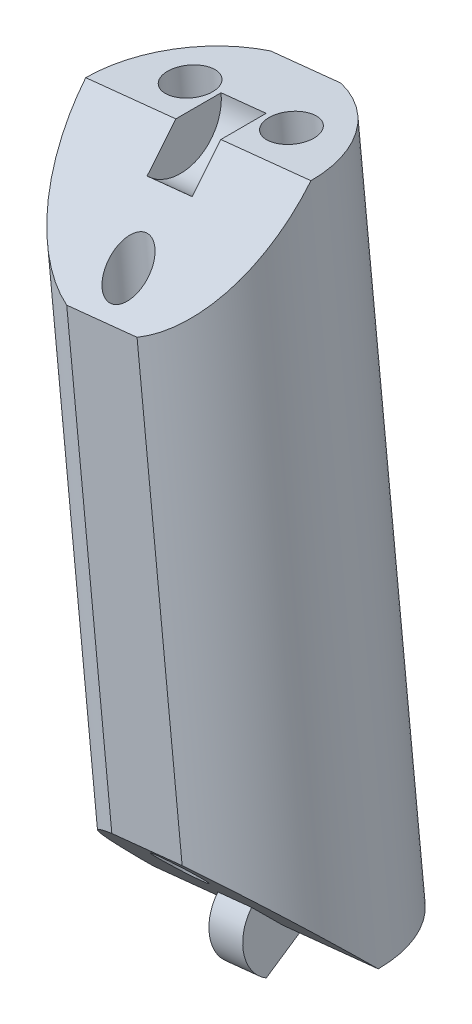
from build123d import *

# Parameters (mm, degrees)
SKETCH3_R               = 8
BOSS_EXTRUDE1_DEPTH     = 46.103684211
CUT_EXTRUDE1_DEPTH      = 13.730251515
CUT_EXTRUDE1_DEPTH_BACK = 13.730251515
BOSS_EXTRUDE2_DEPTH     = 1.2
CUT_EXTRUDE2_DEPTH      = 1.6
SKETCH8_R               = 1.4
SKETCH8_R_2             = 1.6
CUT_EXTRUDE3_DEPTH      = 2.64160469
CUT_EXTRUDE3_DEPTH_BACK = 50.446677335
CUT_EXTRUDE4_DEPTH      = 50.446677335


with BuildPart() as part:
    # Sketch3 → Boss-Extrude1 (new body)
    with BuildSketch(Plane(origin=(-20.344467381, 196.178792599, 0), x_dir=(-0.994665758, -0.103150523, 0), z_dir=(0.103150523, -0.994665758, 0))):
        with Locations((-10.431405186, 0)):
            Circle(SKETCH3_R)
    extrude(amount=BOSS_EXTRUDE1_DEPTH)

    # Sketch4 → Cut-Extrude1 (cut, two sides)
    with BuildSketch(Plane(origin=(10.375761543, 1.076004901, 0), x_dir=(0.103150523, -0.994665758, 0), z_dir=(-0.994665758, -0.103150523, 0))) as cut_extrude1_sk:
        Polygon((-197.230869842, 0), (-189.230869842, 8), (-197.230869842, 8), align=None)
        Polygon((-159.127185631, 8), (-151.127185631, 8), (-151.127185631, 0), align=None)
    extrude(amount=CUT_EXTRUDE1_DEPTH, mode=Mode.SUBTRACT)
    extrude(cut_extrude1_sk.sketch, amount=-CUT_EXTRUDE1_DEPTH_BACK, mode=Mode.SUBTRACT)

    # Sketch5 → Boss-Extrude2 (add, symmetric)
    with BuildSketch(Plane(origin=(10.375761543, 1.076004901, 0), x_dir=(0.103150523, -0.994665758, 0), z_dir=(-0.994665758, -0.103150523, 0))):
        with BuildLine():
            Line((-151.127185631, -2.8), (-148.702314501, 1.4))
            ThreePointArc((-148.702314501, 1.4), (-150.761712293, 2.776045612), (-153.107084619, 1.979898987))
            Line((-153.107084619, 1.979898987), (-151.127185631, 0))
            Line((-151.127185631, 0), (-151.127185631, -2.8))
        make_face()
    extrude(amount=BOSS_EXTRUDE2_DEPTH, both=True)

    # Sketch7 → Cut-Extrude2 (cut, symmetric)
    with BuildSketch(Plane(origin=(10.375761543, 1.076004901, 0), x_dir=(0.103150523, -0.994665758, 0), z_dir=(-0.994665758, -0.103150523, 0))):
        with BuildLine():
            Line((-194.968128142, 2.2627417), (-197.230869842, 0))
            Line((-197.230869842, 0), (-197.230869842, -3.2))
            ThreePointArc((-197.230869842, -3.2), (-194.274455338, -1.224586984), (-194.968128142, 2.2627417))
        make_face()
    extrude(amount=CUT_EXTRUDE2_DEPTH, both=True, mode=Mode.SUBTRACT)

    # Sketch8 → Cut-Extrude3 (cut, two sides)
    with BuildSketch(Plane(origin=(-20.344467381, 196.178792599, 0), x_dir=(0.994665758, 0.103150523, 0), z_dir=(-0.103150523, 0.994665758, 0))) as cut_extrude3_sk:
        with Locations((10.431405186, -5.5)):
            Circle(SKETCH8_R)
        with Locations((6.831405186, 3)):
            Circle(SKETCH8_R_2)
        with Locations((14.031405186, 3)):
            Circle(SKETCH8_R_2)
    extrude(amount=CUT_EXTRUDE3_DEPTH, mode=Mode.SUBTRACT)
    extrude(cut_extrude3_sk.sketch, amount=-CUT_EXTRUDE3_DEPTH_BACK, mode=Mode.SUBTRACT)

    # Sketch9 → Cut-Extrude4 (cut, through all)
    with BuildSketch(Plane(origin=(-20.344467381, 196.178792599, 0), x_dir=(0.994665758, 0.103150523, 0), z_dir=(-0.103150523, 0.994665758, 0))):
        with BuildLine():
            Line((7.933405986, 7.6), (12.929404385, 7.6))
            ThreePointArc((12.929404385, 7.6), (10.431405186, 8), (7.933405986, 7.6))
        make_face()
        with BuildLine():
            Line((7.933405986, -7.6), (12.929404385, -7.6))
            ThreePointArc((12.929404385, -7.6), (10.431405186, -8), (7.933405986, -7.6))
        make_face()
    extrude(amount=-CUT_EXTRUDE4_DEPTH, mode=Mode.SUBTRACT)


solid = part.part
